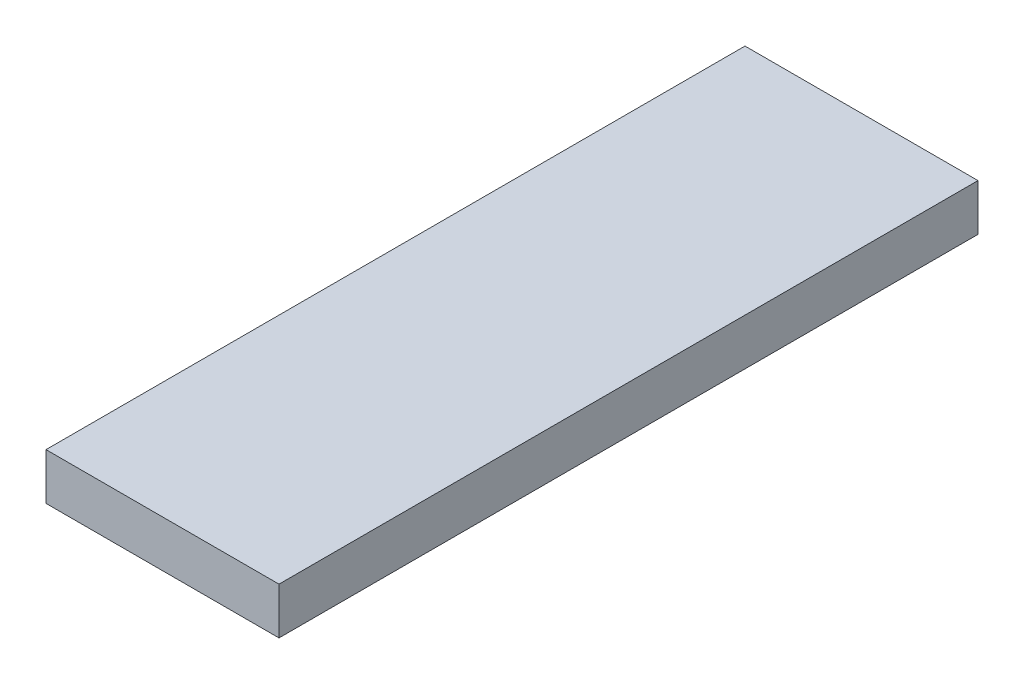
from build123d import *

# Parameters (mm, degrees)
SKETCH_1_W      = 10
SKETCH_1_H      = 30
EXTRUDE_1_DEPTH = 2


with BuildPart() as part:
    # 草图1 → 凸台-拉伸1 (new body)
    with BuildSketch(Plane(origin=(0, 0, 0), x_dir=(1, 0, 0), z_dir=(0, 1, 0))):
        with Locations((-12.848353068, 3.715981342)):
            Rectangle(SKETCH_1_W, SKETCH_1_H)
    extrude(amount=EXTRUDE_1_DEPTH)


solid = part.part
